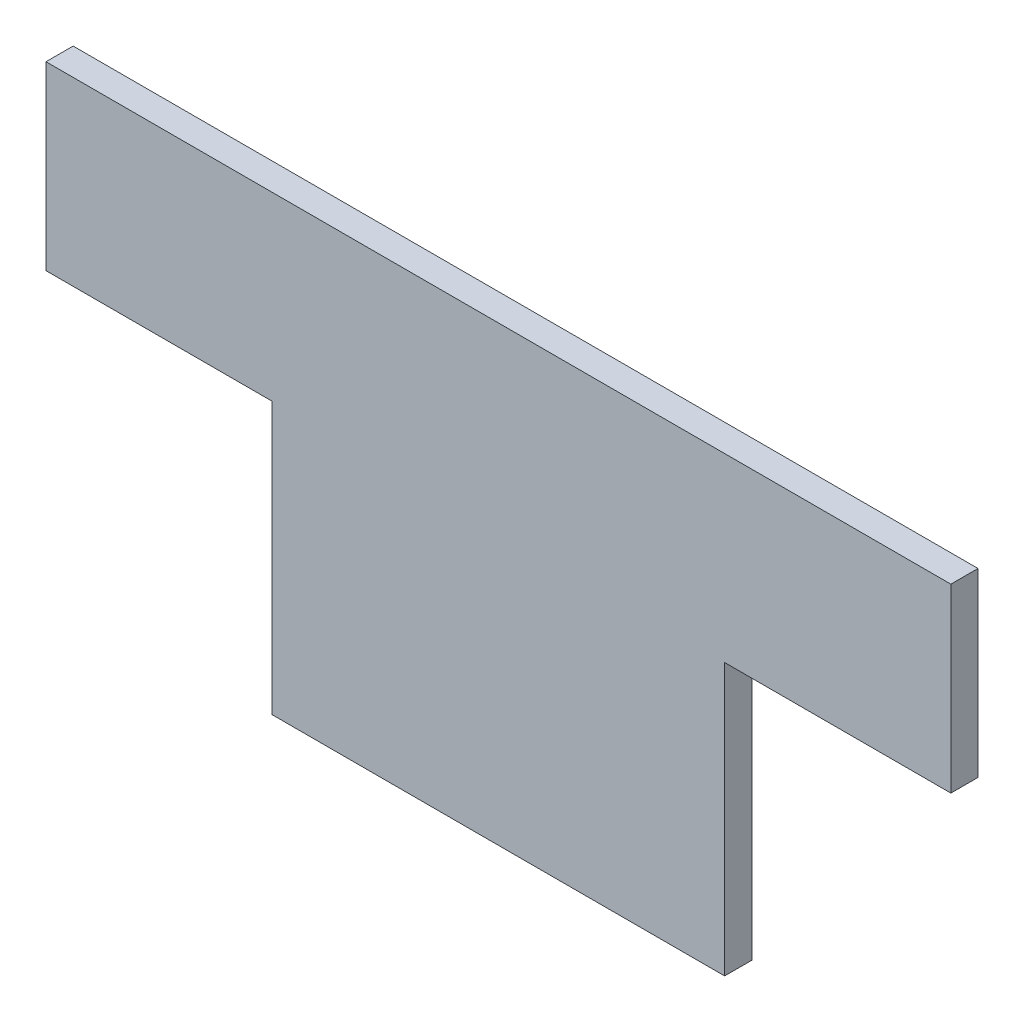
from build123d import *

# Parameters (mm, degrees)
BOSS_EXTRUDE1_DEPTH = 3


with BuildPart() as part:
    # Sketch2 → Boss-Extrude1 (new body)
    with BuildSketch(Plane.XY):
        Polygon((-50, 25), (50, 25), (50, 5), (25, 5), (25, -25), (-25, -25), (-25, 5), (-50, 5), align=None)
    extrude(amount=BOSS_EXTRUDE1_DEPTH)


solid = part.part
